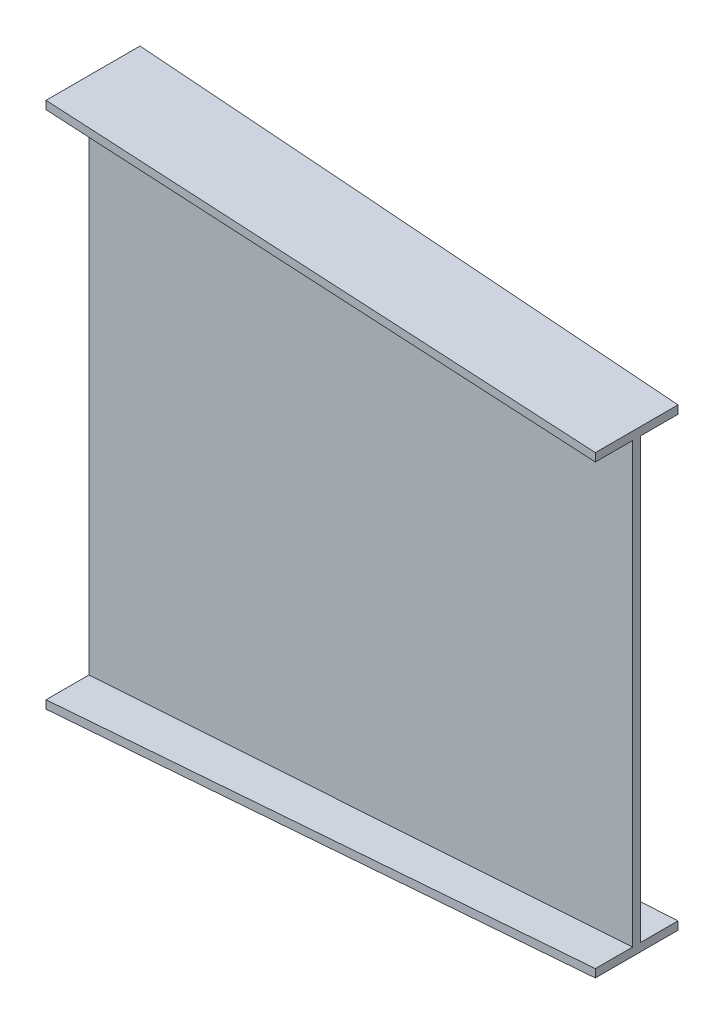
from build123d import *


with BuildPart() as part:
    # Sketch1 → Loft l1 section 0
    with BuildSketch(Plane(origin=(0, 0, 0), x_dir=(0, 0, -1), z_dir=(1, 0, 0))):
        Polygon((-94, 485), (79, 485), (79, 470), (0, 470), (0, -470), (79, -470), (79, -485), (-94, -485), (-94, -470), (-15, -470), (-15, 470), (-94, 470), align=None)
    # Sketch4 → Loft l1 section 1
    with BuildSketch(Plane(origin=(1000, 0, -1000), x_dir=(0, 0, 1), z_dir=(-1, 0, 0))):
        Polygon((931.5, 418.5), (1083.5, 418.5), (1083.5, 403.5), (1015, 403.5), (1015, -403.5), (1083.5, -403.5), (1083.5, -418.5), (931.5, -418.5), (931.5, -403.5), (1000, -403.5), (1000, 403.5), (931.5, 403.5), align=None)
    loft()


solid = part.part
